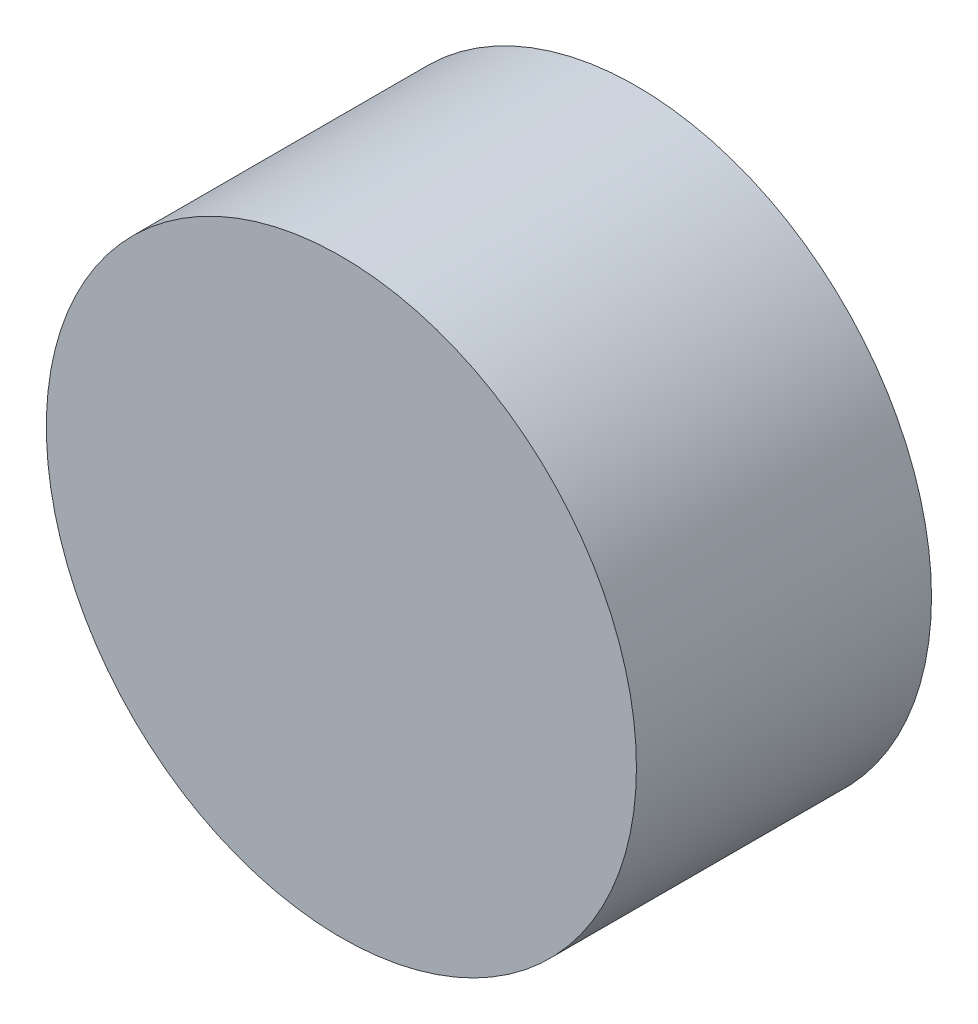
from build123d import *

# Parameters (mm, degrees)
SKETCH1_R           = 203.2
BOSS_EXTRUDE1_DEPTH = 101.6


with BuildPart() as part:
    # Sketch1 → Boss-Extrude1 (new body, symmetric)
    with BuildSketch(Plane.XY):
        Circle(SKETCH1_R)
    extrude(amount=BOSS_EXTRUDE1_DEPTH, both=True)


solid = part.part
